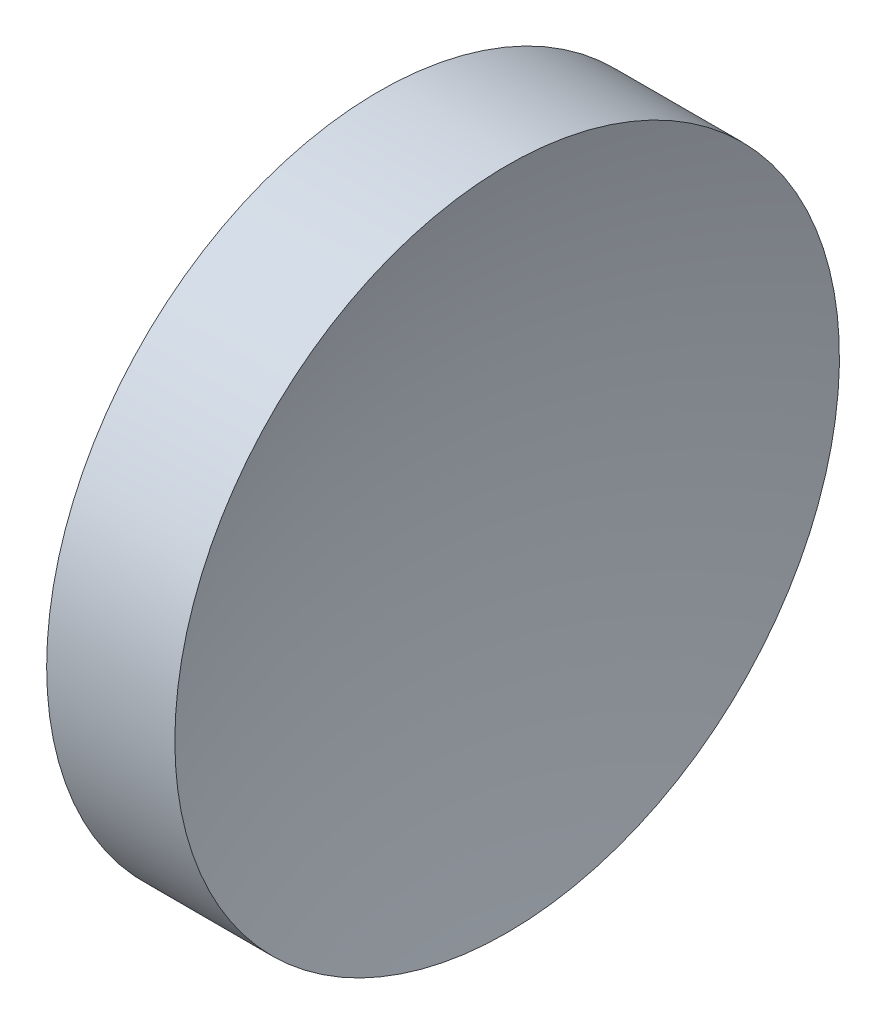
from build123d import *


with BuildPart() as part:
    # 草图1 → 旋转1 (revolve)
    with BuildSketch(Plane.XY, mode=Mode.PRIVATE) as revolve_1_sk:
        with BuildLine():
            Line((119.506834179, 71.193989087), (119.506834179, 83.893989087))
            Line((119.506834179, 83.893989087), (124.406593215, 83.893989087))
            ThreePointArc((124.406593215, 83.893989087), (122.984401478, 77.614641008), (122.506834179, 71.193989087))
            Line((122.506834179, 71.193989087), (119.506834179, 71.193989087))
        make_face()
    revolve(revolve_1_sk.sketch.rotate(Axis((111.955229758, 71.193989087, 0), (1, 0, 0)), 180), axis=Axis((111.955229758, 71.193989087, 0), (1, 0, 0)))  # turned: the seam where the file's is


solid = part.part
